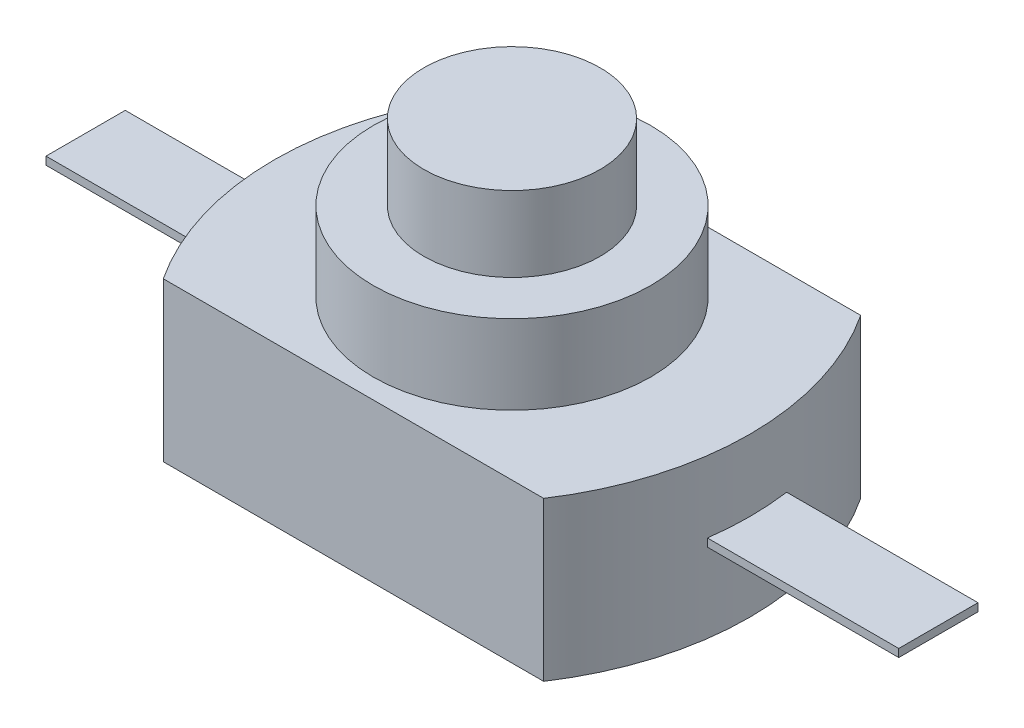
from build123d import *

# Parameters (mm, degrees)
SKETCH1_W           = 9.6
SKETCH1_H           = 8
BOSS_EXTRUDE1_DEPTH = 4
SKETCH2_R           = 3.5
BOSS_EXTRUDE2_DEPTH = 2
SKETCH3_R           = 2.225
BOSS_EXTRUDE3_DEPTH = 1.9
BOSS_EXTRUDE4_START = -2
SKETCH4_W           = 5.092025843
SKETCH4_H           = 2
BOSS_EXTRUDE4_DEPTH = 0.2


with BuildPart() as part:
    # Sketch1 → Boss-Extrude1 (new body)
    with BuildSketch(Plane(origin=(0, 0, 0), x_dir=(1, 0, 0), z_dir=(0, 1, 0))):
        with Locations((4.8, -4)):
            Rectangle(SKETCH1_W, SKETCH1_H)
        with BuildLine():
            Line((0, 0), (0, -8))
            ThreePointArc((0, -8), (-1.2, -4), (0, 0))
        make_face()
        with BuildLine():
            ThreePointArc((9.6, 0), (10.8, -4), (9.6, -8))
            Line((9.6, -8), (9.6, 0))
        make_face()
    extrude(amount=BOSS_EXTRUDE1_DEPTH)

    # Sketch2 → Boss-Extrude2 (add)
    with BuildSketch(Plane(origin=(0, 4, 0), x_dir=(1, 0, 0), z_dir=(0, 1, 0))):
        with Locations((4.8, -4)):
            Circle(SKETCH2_R)
    extrude(amount=BOSS_EXTRUDE2_DEPTH)

    # Sketch3 → Boss-Extrude3 (add)
    with BuildSketch(Plane(origin=(0, 6, 0), x_dir=(1, 0, 0), z_dir=(0, 1, 0))):
        with Locations((4.8, -4)):
            Circle(SKETCH3_R)
    extrude(amount=BOSS_EXTRUDE3_DEPTH)

    # Sketch4 → Boss-Extrude4 (add)
    with BuildSketch(Plane(origin=(0, 4, 0), x_dir=(1, 0, 0), z_dir=(0, 1, 0)).offset(BOSS_EXTRUDE4_START)):
        with Locations((-3.414000557, -4)):
            Rectangle(SKETCH4_W, SKETCH4_H)
        with Locations((13.014000557, -4)):
            Rectangle(SKETCH4_W, SKETCH4_H)
    extrude(amount=BOSS_EXTRUDE4_DEPTH)


solid = part.part
